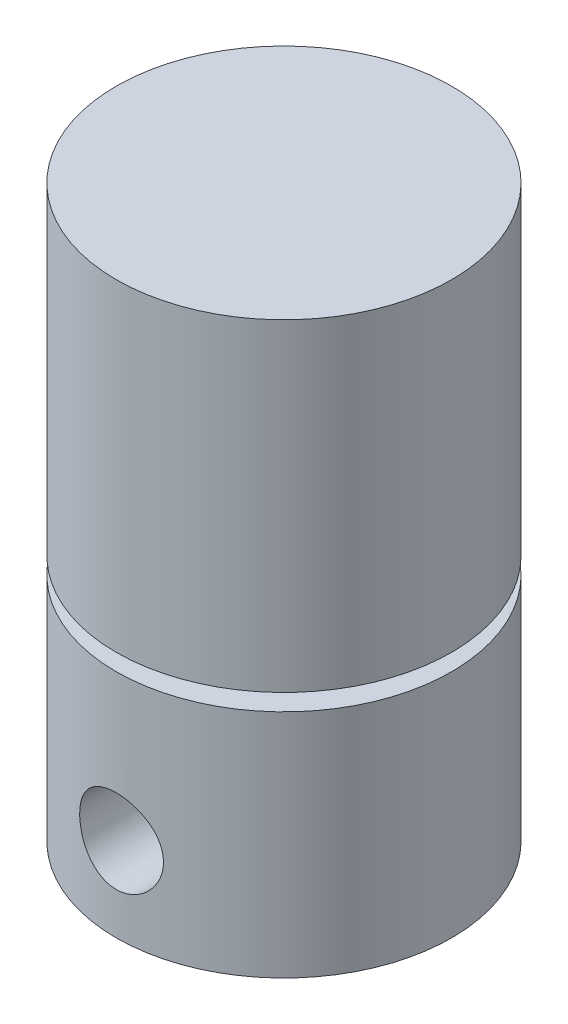
from build123d import *

# Parameters (mm, degrees)
SKETCH1_R           = 12.7
BOSS_EXTRUDE1_DEPTH = 17.4625
SKETCH2_R           = 9.525
BOSS_EXTRUDE2_DEPTH = 1.27
SKETCH3_R           = 12.7
BOSS_EXTRUDE3_DEPTH = 24.4475
CUT_EXTRUDE1_REACH  = 21.05
CUT_EXTRUDE1_START  = 6.35
SKETCH4_R           = 3.175
CUT_EXTRUDE2_REACH  = 24.098
CUT_EXTRUDE2_START  = -9.398
SKETCH5_R           = 3.175
SKETCH6_R           = 1.5875
CUT_EXTRUDE3_DEPTH  = 6.35


with BuildPart() as part:
    # Sketch1 → Boss-Extrude1 (new body)
    with BuildSketch(Plane(origin=(0, 0, 0), x_dir=(1, 0, 0), z_dir=(0, 1, 0))):
        Circle(SKETCH1_R)
    extrude(amount=BOSS_EXTRUDE1_DEPTH)

    # Sketch2 → Boss-Extrude2 (add)
    with BuildSketch(Plane(origin=(0, 17.4625, 0), x_dir=(1, 0, 0), z_dir=(0, 1, 0))):
        Circle(SKETCH2_R)
    extrude(amount=BOSS_EXTRUDE2_DEPTH)

    # Sketch3 → Boss-Extrude3 (add)
    with BuildSketch(Plane(origin=(0, 18.7325, 0), x_dir=(1, 0, 0), z_dir=(0, 1, 0))):
        Circle(SKETCH3_R)
    extrude(amount=BOSS_EXTRUDE3_DEPTH)

    # Sketch4 → Cut-Extrude1 (cut, up to next)
    with BuildSketch(Plane.XY.offset(CUT_EXTRUDE1_START), mode=Mode.PRIVATE) as cut_extrude1_sk1:
        with Locations((0, 6.35)):
            Circle(SKETCH4_R)
    cut_extrude1_tool1 = extrude(cut_extrude1_sk1.sketch, amount=CUT_EXTRUDE1_REACH, mode=Mode.PRIVATE) & part.part
    add(cut_extrude1_tool1.solids().sort_by_distance((0, 6.35, 6.35))[0], mode=Mode.SUBTRACT)

    # Sketch5 → Cut-Extrude2 (cut, up to next)
    with BuildSketch(Plane.XY.offset(CUT_EXTRUDE2_START), mode=Mode.PRIVATE) as cut_extrude2_sk1:
        with Locations((0, 6.35)):
            Circle(SKETCH5_R)
    cut_extrude2_tool1 = extrude(cut_extrude2_sk1.sketch, amount=-CUT_EXTRUDE2_REACH, mode=Mode.PRIVATE) & part.part
    add(cut_extrude2_tool1.solids().sort_by_distance((0, 6.35, -9.398))[0], mode=Mode.SUBTRACT)

    # Sketch6 → Cut-Extrude3 (cut)
    with BuildSketch(Plane(origin=(0, 0, 0), x_dir=(-1, 0, 0), z_dir=(0, -1, 0))):
        with Locations((-9.525, 0)):
            Circle(SKETCH6_R)
        with Locations((9.525, 0)):
            Circle(SKETCH6_R)
    extrude(amount=-CUT_EXTRUDE3_DEPTH, mode=Mode.SUBTRACT)


solid = part.part
